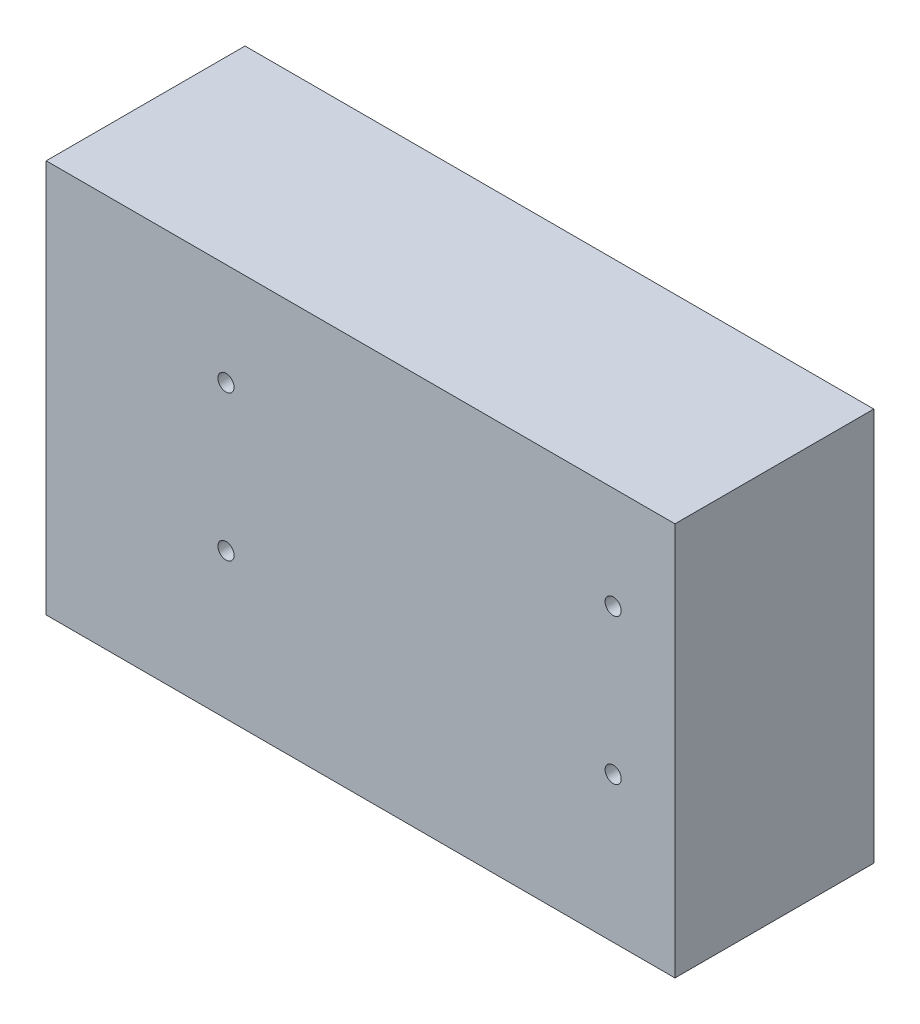
from build123d import *

# Parameters (mm, degrees)
SKETCH1_W           = 66.1
SKETCH1_H           = 41.35
BOSS_EXTRUDE1_DEPTH = 20.9
SKETCH2_R           = 0.85
CUT_EXTRUDE1_DEPTH  = 30


with BuildPart() as part:
    # Sketch1 → Boss-Extrude1 (new body)
    with BuildSketch(Plane.XY):
        Rectangle(SKETCH1_W, SKETCH1_H)
    extrude(amount=BOSS_EXTRUDE1_DEPTH)

    # Sketch2 → Cut-Extrude1 (cut)
    with BuildSketch(Plane(origin=(0, 0, 0), x_dir=(-1, 0, 0), z_dir=(0, 0, -1))):
        with Locations((-26.55, 9.925)):
            Circle(SKETCH2_R)
        with Locations((-26.55, -5.375)):
            Circle(SKETCH2_R)
        with Locations((14.15, 9.925)):
            Circle(SKETCH2_R)
        with Locations((14.15, -5.375)):
            Circle(SKETCH2_R)
    extrude(amount=-CUT_EXTRUDE1_DEPTH, mode=Mode.SUBTRACT)


solid = part.part
